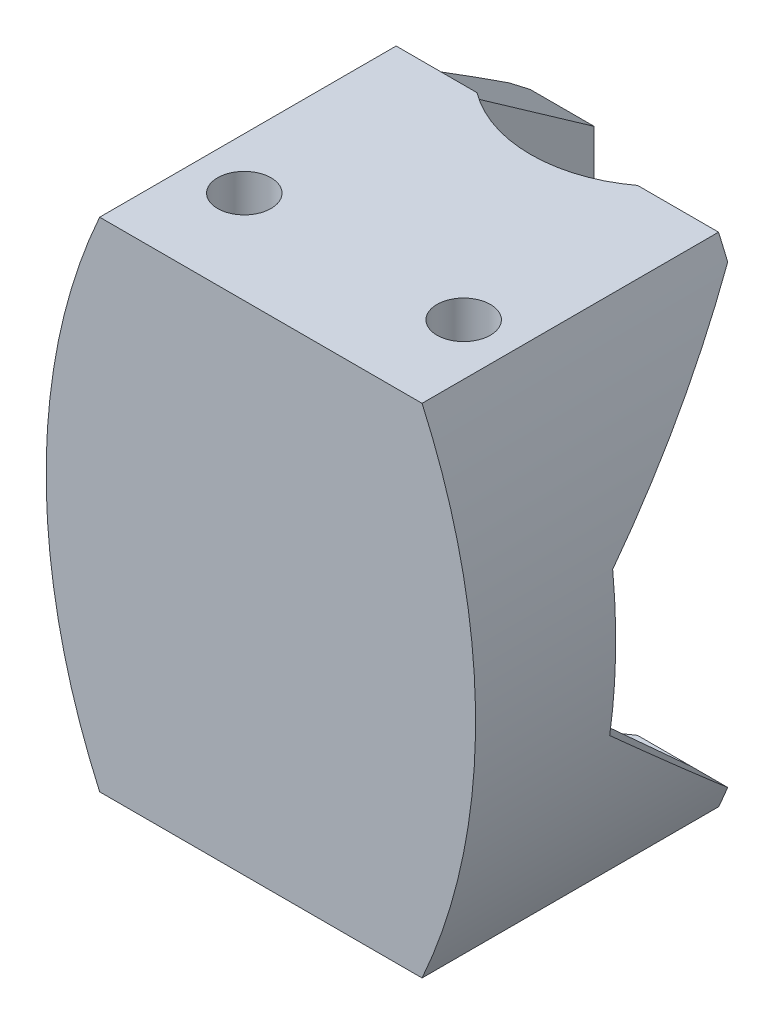
from build123d import *

# Parameters (mm, degrees)
BOSS_EXTRUDE1_DEPTH     = 32.5
SKETCH4_R               = 1.05
BOSS_EXTRUDE2_DEPTH     = 2
SKETCH7_R               = 2.495
WIRE_SPACING2_DEPTH     = 3
SKETCH8_W               = 30.122
SKETCH8_H               = 37.7
SKETCH8_R               = 2.495
BOSS_EXTRUDE6_DEPTH     = 2
SKETCH5_R               = 1.05
BOSS_EXTRUDE3_DEPTH     = 2
SKETCH9_R               = 2.495
WIRE_SPACING1_DEPTH     = 3
SKETCH10_W              = 30.122
SKETCH10_H              = 37.7
SKETCH10_R              = 2.495
BOSS_EXTRUDE8_DEPTH     = 2
SKETCH11_R              = 12.5
CUT_EXTRUDE1_DEPTH      = 47.5
SKETCH18_W              = 10
SKETCH18_H              = 10
CUT_EXTRUDE4_DEPTH      = 47.5
BOSS_EXTRUDE10_DEPTH    = 2.5
BOSS_EXTRUDE11_DEPTH    = 2.5
BOSS_EXTRUDE12_DEPTH    = 43.7
CUT_EXTRUDE5_DEPTH      = 21.061
CUT_EXTRUDE5_DEPTH_BACK = 21.061
CUT_EXTRUDE7_DEPTH      = 8.5
CUT_EXTRUDE8_DEPTH      = 47.5


with BuildPart() as part:
    # Sketch2 → Boss-Extrude1 (new body)
    with BuildSketch(Plane(origin=(0, 0, 0), x_dir=(1, 0, 0), z_dir=(0, 1, 0))):
        Polygon((15.061, 0), (15.061, 37.7), (12.561, 37.7), (12.561, 2.5), (-12.561, 2.5), (-12.561, 37.7), (-15.061, 37.7), (-15.061, 0), align=None)
    extrude(amount=BOSS_EXTRUDE1_DEPTH)

    # Sketch4 → Boss-Extrude2 (add)
    with BuildSketch(Plane.XZ):
        Polygon((-15.061, 0), (-15.061, -7.443777264), (-15.061, -37.7), (-12.561, -37.7), (-12.561, -7.5), (12.561, -7.5), (12.561, -37.7), (15.061, -37.7), (15.061, -7.443777264), (15.061, 0), align=None)
        with Locations((-10.2499, -4.95)):
            Circle(SKETCH4_R, mode=Mode.SUBTRACT)
        with Locations((10.2499, -4.95)):
            Circle(SKETCH4_R, mode=Mode.SUBTRACT)
    extrude(amount=BOSS_EXTRUDE2_DEPTH)

    # Sketch7 → Wire spacing2 (add)
    with BuildSketch(Plane.XZ.offset(2)):
        Polygon((-15.061, 0), (-15.061, -37.7), (-12.561, -37.7), (-12.561, -7.5), (12.561, -7.5), (12.561, -37.7), (15.061, -37.7), (15.061, 0), align=None)
        with Locations((-10.2499, -4.95)):
            Circle(SKETCH7_R, mode=Mode.SUBTRACT)
        with Locations((10.2499, -4.95)):
            Circle(SKETCH7_R, mode=Mode.SUBTRACT)
    extrude(amount=WIRE_SPACING2_DEPTH)

    # Sketch8 → Boss-Extrude6 (add)
    with BuildSketch(Plane.XZ.offset(5)):
        with Locations((0, -18.85)):
            Rectangle(SKETCH8_W, SKETCH8_H)
        with Locations((-10.2499, -4.95)):
            Circle(SKETCH8_R, mode=Mode.SUBTRACT)
        with Locations((10.2499, -4.95)):
            Circle(SKETCH8_R, mode=Mode.SUBTRACT)
    extrude(amount=BOSS_EXTRUDE6_DEPTH)

    # Sketch5 → Boss-Extrude3 (add)
    with BuildSketch(Plane(origin=(0, 32.5, 0), x_dir=(1, 0, 0), z_dir=(0, 1, 0))):
        Polygon((-7.5, 10), (-7.5, 2.5), (7.5, 2.5), (7.5, 10), (10.2499, 12), (12.561, 12), (12.561, 37.7), (15.061, 37.7), (15.061, 0), (-15.061, 0), (-15.061, 37.7), (-12.561, 37.7), (-12.561, 12), (-10.2499, 12), align=None)
        with Locations((-10.2499, 8.7)):
            Circle(SKETCH5_R, mode=Mode.SUBTRACT)
        with Locations((10.2499, 8.7)):
            Circle(SKETCH5_R, mode=Mode.SUBTRACT)
    extrude(amount=BOSS_EXTRUDE3_DEPTH)

    # Sketch9 → Wire spacing1 (add)
    with BuildSketch(Plane(origin=(0, 34.5, 0), x_dir=(1, 0, 0), z_dir=(0, 1, 0))):
        Polygon((-15.061, 0), (-15.061, 37.7), (-12.561, 37.7), (-12.561, 12), (-10.2499, 12), (-7.5, 10), (-7.5, 2.5), (7.5, 2.5), (7.5, 10), (10.2499, 12), (12.561, 12), (12.561, 37.7), (15.061, 37.7), (15.061, 0), align=None)
        with Locations((-10.2499, 8.7)):
            Circle(SKETCH9_R, mode=Mode.SUBTRACT)
        with Locations((10.2499, 8.7)):
            Circle(SKETCH9_R, mode=Mode.SUBTRACT)
    extrude(amount=WIRE_SPACING1_DEPTH)

    # Sketch10 → Boss-Extrude8 (add)
    with BuildSketch(Plane(origin=(0, 37.5, 0), x_dir=(1, 0, 0), z_dir=(0, 1, 0))):
        with Locations((0, 18.85)):
            Rectangle(SKETCH10_W, SKETCH10_H)
        with Locations((-10.2499, 8.7)):
            Circle(SKETCH10_R, mode=Mode.SUBTRACT)
        with Locations((10.2499, 8.7)):
            Circle(SKETCH10_R, mode=Mode.SUBTRACT)
    extrude(amount=BOSS_EXTRUDE8_DEPTH)

    # Sketch11 → Cut-Extrude1 (cut, through all)
    with BuildSketch(Plane(origin=(0, 39.5, 0), x_dir=(1, 0, 0), z_dir=(0, 1, 0))):
        with Locations((0, 37.7)):
            Circle(SKETCH11_R)
    extrude(amount=-CUT_EXTRUDE1_DEPTH, mode=Mode.SUBTRACT)

    # Sketch18 → Cut-Extrude4 (cut, through all)
    with BuildSketch(Plane(origin=(0, 39.5, 0), x_dir=(1, 0, 0), z_dir=(0, 1, 0))):
        with Locations((-10.061, 32.7)):
            Rectangle(SKETCH18_W, SKETCH18_H)
        with Locations((10.061, 32.7)):
            Rectangle(SKETCH18_W, SKETCH18_H)
    extrude(amount=-CUT_EXTRUDE4_DEPTH, mode=Mode.SUBTRACT)

    # Sketch19 → Boss-Extrude10 (add)
    with BuildSketch(Plane.ZY.offset(15.061)):
        Polygon((-27.7, 37.5), (-43.7, 26.25), (-43.7, 6.25), (-27.7, -5), align=None)
    extrude(amount=-BOSS_EXTRUDE10_DEPTH)

    # Sketch20 → Boss-Extrude11 (add)
    with BuildSketch(Plane(origin=(15.061, 0, 0), x_dir=(0, 0, -1), z_dir=(1, 0, 0))):
        Polygon((27.7, 37.5), (43.7, 26.25), (43.7, 6.25), (27.7, -5), align=None)
    extrude(amount=-BOSS_EXTRUDE11_DEPTH)

    # Sketch21 → Boss-Extrude12 (add)
    with BuildSketch(Plane.XY):
        with BuildLine():
            Line((15.061, 39.5), (15.061, -7))
            ThreePointArc((15.061, -7), (20.061, 16.25), (15.061, 39.5))
        make_face()
        with BuildLine():
            Line((-15.061, 39.5), (-15.061, -7))
            ThreePointArc((-15.061, -7), (-20.061, 16.25), (-15.061, 39.5))
        make_face()
    extrude(amount=-BOSS_EXTRUDE12_DEPTH)

    # Sketch22 → Cut-Extrude5 (cut, two sides)
    with BuildSketch(Plane(origin=(0, 0, 0), x_dir=(0, 0, -1), z_dir=(1, 0, 0))) as cut_extrude5_sk:
        Polygon((27.7, 37.5), (27.7, 39.5), (50.372745126, 39.5), (50.372745126, -11.616849197), (27.7, -11.616849197), (27.7, -5), (43.7, 6.25), (43.7, 26.25), align=None)
    extrude(amount=CUT_EXTRUDE5_DEPTH, mode=Mode.SUBTRACT)
    extrude(cut_extrude5_sk.sketch, amount=-CUT_EXTRUDE5_DEPTH_BACK, mode=Mode.SUBTRACT)

    # Sketch23 → Cut-Extrude7 (cut, through all)
    with BuildSketch(Plane.ZY.offset(-12.561)):
        Polygon((-27.7, 37.5), (-13.091239011, 21.881848889), (-13.091239011, 8.292742538), (-27.7, -5), (-48.045036631, -3.33430033), (-49.353078953, 36.560990509), align=None)
    extrude(amount=-CUT_EXTRUDE7_DEPTH, mode=Mode.SUBTRACT)

    # Sketch24 → Cut-Extrude8 (cut, through all)
    with BuildSketch(Plane.XZ.offset(7)):
        with BuildLine():
            Line((-19.53, -76.468982583), (19.53, -77.324698996))
            Line((19.53, -77.324698996), (19.53, -37.5))
            ThreePointArc((19.53, -37.5), (0, -57.03), (-19.53, -37.5))
            Line((-19.53, -37.5), (-36.23071583, -37.5))
            Line((-36.23071583, -37.5), (-36.23071583, -76.468982583))
            Line((-36.23071583, -76.468982583), (-19.53, -76.468982583))
        make_face()
    extrude(amount=-CUT_EXTRUDE8_DEPTH, mode=Mode.SUBTRACT)


solid = part.part
